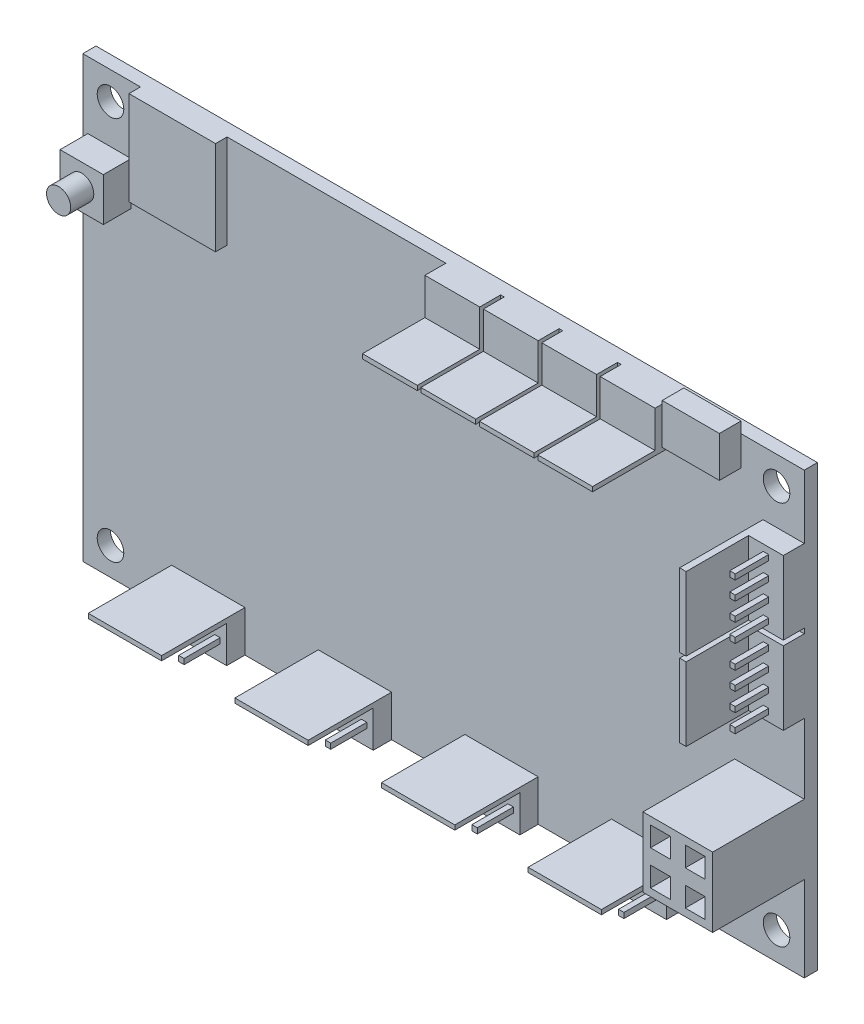
from build123d import *

# Parameters (mm, degrees)
SKETCH1_W             = 100
SKETCH1_H             = 60.96
BOSS_EXTRUDE1_DEPTH   = 1.8288
SKETCH2_W             = 10.16
SKETCH2_H             = 5.715
SKETCH2_W_2           = 5.715
SKETCH2_H_2           = 10.16
F_4_PIN_MOLEX_DEPTH   = 11.557
SKETCH3_W             = 9.017
SKETCH3_H             = 5.08
CUT_EXTRUDE1_DEPTH    = 84.439
SKETCH7_W             = 4.815
SKETCH7_H             = 8.657
CUT_EXTRUDE2_DEPTH    = 24.6
SKETCH4_W             = 9.652
SKETCH4_H             = 9.652
POWER_CONNECTOR_DEPTH = 12.7
SKETCH5_W             = 7.9248
SKETCH5_H             = 5.6388
MICROUSB_DEPTH        = 3
SKETCH6_W             = 12
SKETCH6_H             = 13
MICROSD_DEPTH         = 1.6
SKETCH8_W             = 6
SKETCH8_H             = 6
BOSS_EXTRUDE6_DEPTH   = 3.85
SKETCH9_R             = 1.675
BOSS_EXTRUDE7_DEPTH   = 3.2
SKETCH10_W            = 7.6
SKETCH10_H            = 5.715
BOSS_EXTRUDE8_DEPTH   = 11.557
SKETCH11_W            = 8.657
SKETCH11_H            = 5.08
CUT_EXTRUDE3_DEPTH    = 36.449
SKETCH13_R            = 1.8415
CUT_EXTRUDE4_DEPTH    = 36.449
SKETCH14_W            = 2.75
SKETCH14_H            = 2.75
CUT_EXTRUDE5_DEPTH    = 5
SKETCH15_W            = 0.75
SKETCH15_H            = 0.75
BOSS_EXTRUDE9_DEPTH   = 5


with BuildPart() as part:
    # Sketch1 → Boss-Extrude1 (new body)
    with BuildSketch(Plane.XY):
        with Locations((50, 30.48)):
            Rectangle(SKETCH1_W, SKETCH1_H)
    extrude(amount=BOSS_EXTRUDE1_DEPTH)

    # Sketch2 → 4 pin molex (add)
    with BuildSketch(Plane.XY.offset(1.8288)):
        with Locations((17.399, 2.8575)):
            Rectangle(SKETCH2_W, SKETCH2_H)
        with Locations((37.719, 2.8575)):
            Rectangle(SKETCH2_W, SKETCH2_H)
        with Locations((58.039, 2.8575)):
            Rectangle(SKETCH2_W, SKETCH2_H)
        with Locations((78.359, 2.8575)):
            Rectangle(SKETCH2_W, SKETCH2_H)
        with Locations((97.1425, 47.08)):
            Rectangle(SKETCH2_W_2, SKETCH2_H_2)
        with Locations((97.1425, 36.24)):
            Rectangle(SKETCH2_W_2, SKETCH2_H_2)
    extrude(amount=F_4_PIN_MOLEX_DEPTH)

    # Sketch3 → Cut-Extrude1 (cut, through all)
    with BuildSketch(Plane(origin=(83.439, 0, 0), x_dir=(0, 0, -1), z_dir=(1, 0, 0))):
        with Locations((-8.8773, 2.54)):
            Rectangle(SKETCH3_W, SKETCH3_H)
    extrude(amount=-CUT_EXTRUDE1_DEPTH, mode=Mode.SUBTRACT)

    # Sketch7 → Cut-Extrude2 (cut)
    with BuildSketch(Plane(origin=(0, 31.16, 0), x_dir=(-1, 0, 0), z_dir=(0, -1, 0))):
        with Locations((-97.5925, -9.0573)):
            Rectangle(SKETCH7_W, SKETCH7_H)
    extrude(amount=-CUT_EXTRUDE2_DEPTH, mode=Mode.SUBTRACT)

    # Sketch4 → Power Connector (add)
    with BuildSketch(Plane.XY.offset(1.8288)):
        with Locations((95.174, 16.637)):
            Rectangle(SKETCH4_W, SKETCH4_H)
    extrude(amount=POWER_CONNECTOR_DEPTH)

    # Sketch5 → MicroUSB (add)
    with BuildSketch(Plane.XY.offset(1.8288)):
        with Locations((87.2746, 59.6646)):
            Rectangle(SKETCH5_W, SKETCH5_H)
    extrude(amount=MICROUSB_DEPTH)

    # Sketch6 → MicroSD (add)
    with BuildSketch(Plane.XY.offset(1.8288)):
        with Locations((14, 54.46)):
            Rectangle(SKETCH6_W, SKETCH6_H)
    extrude(amount=MICROSD_DEPTH)

    # Sketch8 → Boss-Extrude6 (add)
    with BuildSketch(Plane.XY.offset(1.8288)):
        with Locations((3.7, 48.71)):
            Rectangle(SKETCH8_W, SKETCH8_H)
    extrude(amount=BOSS_EXTRUDE6_DEPTH)

    # Sketch9 → Boss-Extrude7 (add)
    with BuildSketch(Plane.XY.offset(5.6788)):
        with Locations((3.7, 48.71)):
            Circle(SKETCH9_R)
    extrude(amount=BOSS_EXTRUDE7_DEPTH)

    # Sketch10 → Boss-Extrude8 (add)
    with BuildSketch(Plane.XY.offset(1.8288)):
        with Locations((78.42, 58.1025)):
            Rectangle(SKETCH10_W, SKETCH10_H)
        with Locations((70.32, 58.1025)):
            Rectangle(SKETCH10_W, SKETCH10_H)
        with Locations((62.22, 58.1025)):
            Rectangle(SKETCH10_W, SKETCH10_H)
        with Locations((54.12, 58.1025)):
            Rectangle(SKETCH10_W, SKETCH10_H)
    extrude(amount=BOSS_EXTRUDE8_DEPTH)

    # Sketch11 → Cut-Extrude3 (cut)
    with BuildSketch(Plane(origin=(82.22, 0, 0), x_dir=(0, 0, -1), z_dir=(1, 0, 0))):
        with Locations((-9.0573, 58.42)):
            Rectangle(SKETCH11_W, SKETCH11_H)
    extrude(amount=-CUT_EXTRUDE3_DEPTH, mode=Mode.SUBTRACT)

    # Sketch13 → Cut-Extrude4 (cut)
    with BuildSketch(Plane.XY.offset(1.8288)):
        with Locations((3.841500064, 57.1185)):
            Circle(SKETCH13_R)
        with Locations((3.841500064, 3.8415)):
            Circle(SKETCH13_R)
        with Locations((96.1585, 3.8415)):
            Circle(SKETCH13_R)
        with Locations((96.1585, 57.1185)):
            Circle(SKETCH13_R)
    extrude(amount=-CUT_EXTRUDE4_DEPTH, mode=Mode.SUBTRACT)

    # Sketch14 → Cut-Extrude5 (cut)
    with BuildSketch(Plane.XY.offset(14.5288)):
        with Locations((97.587, 14.224)):
            Rectangle(SKETCH14_W, SKETCH14_H)
        with Locations((92.761, 14.224)):
            Rectangle(SKETCH14_W, SKETCH14_H)
        with Locations((92.761, 19.05)):
            Rectangle(SKETCH14_W, SKETCH14_H)
        with Locations((97.587, 19.05)):
            Rectangle(SKETCH14_W, SKETCH14_H)
    extrude(amount=-CUT_EXTRUDE5_DEPTH, mode=Mode.SUBTRACT)

    # Sketch15 → Boss-Extrude9 (add)
    with BuildSketch(Plane.XY.offset(4.3688)):
        with Locations((13.589, 2.54)):
            Rectangle(SKETCH15_W, SKETCH15_H)
        with Locations((16.129, 2.54)):
            Rectangle(SKETCH15_W, SKETCH15_H)
        with Locations((18.669, 2.54)):
            Rectangle(SKETCH15_W, SKETCH15_H)
        with Locations((21.209, 2.54)):
            Rectangle(SKETCH15_W, SKETCH15_H)
        with Locations((33.909, 2.54)):
            Rectangle(SKETCH15_W, SKETCH15_H)
        with Locations((36.449, 2.54)):
            Rectangle(SKETCH15_W, SKETCH15_H)
        with Locations((38.989, 2.54)):
            Rectangle(SKETCH15_W, SKETCH15_H)
        with Locations((41.529, 2.54)):
            Rectangle(SKETCH15_W, SKETCH15_H)
        with Locations((54.229, 2.54)):
            Rectangle(SKETCH15_W, SKETCH15_H)
        with Locations((56.769, 2.54)):
            Rectangle(SKETCH15_W, SKETCH15_H)
        with Locations((59.309, 2.54)):
            Rectangle(SKETCH15_W, SKETCH15_H)
        with Locations((61.849, 2.54)):
            Rectangle(SKETCH15_W, SKETCH15_H)
        with Locations((77.089, 2.54)):
            Rectangle(SKETCH15_W, SKETCH15_H)
        with Locations((74.549, 2.54)):
            Rectangle(SKETCH15_W, SKETCH15_H)
        with Locations((79.629, 2.54)):
            Rectangle(SKETCH15_W, SKETCH15_H)
        with Locations((82.169, 2.54)):
            Rectangle(SKETCH15_W, SKETCH15_H)
        with Locations((97.5925, 32.43)):
            Rectangle(SKETCH15_W, SKETCH15_H)
        with Locations((97.5925, 34.97)):
            Rectangle(SKETCH15_W, SKETCH15_H)
        with Locations((97.5925, 37.51)):
            Rectangle(SKETCH15_W, SKETCH15_H)
        with Locations((97.5925, 40.05)):
            Rectangle(SKETCH15_W, SKETCH15_H)
        with Locations((97.5925, 43.27)):
            Rectangle(SKETCH15_W, SKETCH15_H)
        with Locations((97.5925, 45.81)):
            Rectangle(SKETCH15_W, SKETCH15_H)
        with Locations((97.5925, 48.35)):
            Rectangle(SKETCH15_W, SKETCH15_H)
        with Locations((97.5925, 50.89)):
            Rectangle(SKETCH15_W, SKETCH15_H)
    extrude(amount=BOSS_EXTRUDE9_DEPTH)


solid = part.part
